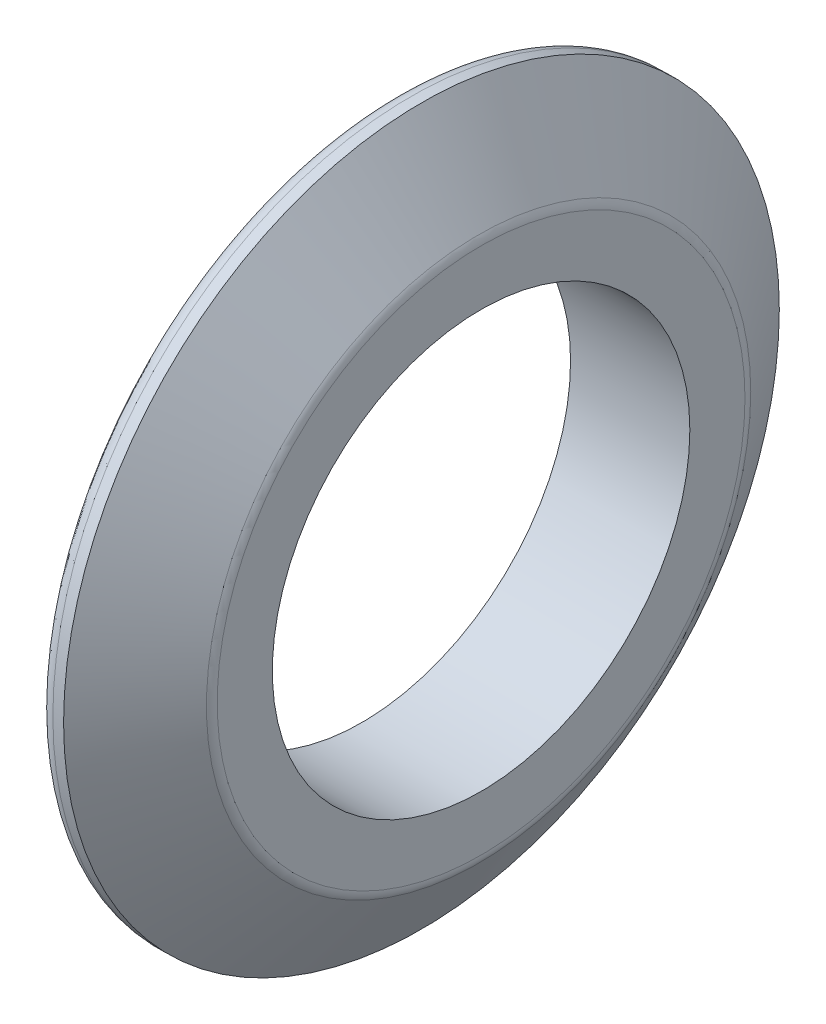
from build123d import *


with BuildPart() as part:
    # Sketch1 → Revolve1 (revolve)
    with BuildSketch(Plane.XY):
        with BuildLine():
            Line((0, 7), (0, 8.848612181))
            ThreePointArc((0, 8.848612181), (-0.021453987, 8.993504255), (-0.083974853, 9.125962279))
            Line((-0.083974853, 9.125962279), (-2, 12))
            Line((-2, 12), (-2.359611797, 12))
            ThreePointArc((-2.359611797, 12), (-2.753714516, 11.807706105), (-2.844683047, 11.378732187))
            Line((-2.844683047, 11.378732187), (-2.155316953, 8.621267813))
            ThreePointArc((-2.155316953, 8.621267813), (-2.246285484, 8.192293895), (-2.640388203, 8))
            Line((-2.640388203, 8), (-3.5, 8))
            ThreePointArc((-3.5, 8), (-3.853553391, 7.853553391), (-4, 7.5))
            Line((-4, 7.5), (-4, 7))
            Line((-4, 7), (0, 7))
        make_face()
    revolve(axis=Axis((0, 0, 0), (-1, 0, 0)))


solid = part.part
